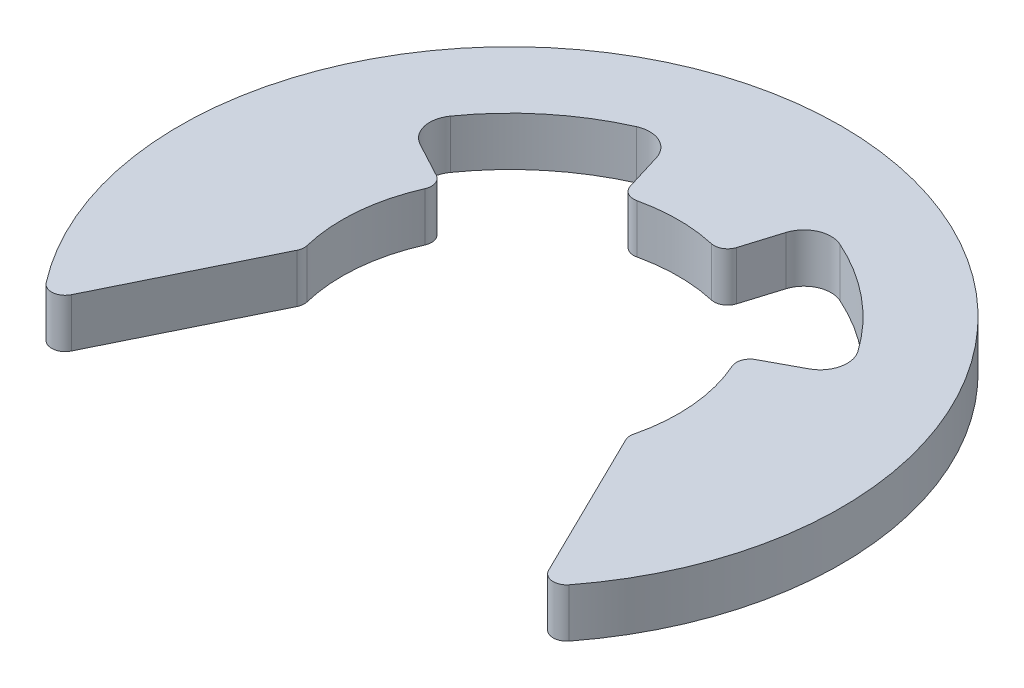
from build123d import *

# Parameters (mm, degrees)
BOSS_EXTRUDE2_DEPTH = 0.9


with BuildPart() as part:
    # Sketch2 → Boss-Extrude2 (new body)
    with BuildSketch(Plane(origin=(0, 0, 0), x_dir=(1, 0, 0), z_dir=(0, 1, 0))):
        with BuildLine():
            Line((-0.980410681, 3.193555213), (-1.194279845, 3.890205091))
            ThreePointArc((-1.194279845, 3.890205091), (-1.465461571, 4.198694788), (-1.876197196, 4.1999862))
            ThreePointArc((-1.876197196, 4.1999862), (-2.921430522, 3.553201895), (-3.758071134, 2.652715844))
            ThreePointArc((-3.758071134, 2.652715844), (-3.836204314, 2.249478162), (-3.585956323, 1.92377682))
            Line((-3.585956323, 1.92377682), (-2.943790684, 1.579270847))
            ThreePointArc((-2.943790684, 1.579270847), (-2.825493737, 1.440063272), (-2.833470582, 1.257554952))
            ThreePointArc((-2.833470582, 1.257554952), (-3.087628894, 0.276672749), (-3.011906881, -0.733768997))
            ThreePointArc((-3.011906881, -0.733768997), (-3.006278091, -0.820065307), (-3.030387689, -0.903116277))
            Line((-3.030387689, -0.903116277), (-4.400044699, -3.693030626))
            ThreePointArc((-4.400044699, -3.693030626), (-4.599153629, -3.831574182), (-4.822086086, -3.735971866))
            ThreePointArc((-4.822086086, -3.735971866), (0, 6.1), (4.822086086, -3.735971866))
            ThreePointArc((4.822086086, -3.735971866), (4.599153629, -3.831574182), (4.400044699, -3.693030626))
            Line((4.400044699, -3.693030626), (3.030387689, -0.903116277))
            ThreePointArc((3.030387689, -0.903116277), (3.006278091, -0.820065307), (3.011906881, -0.733768997))
            ThreePointArc((3.011906881, -0.733768997), (3.087628894, 0.276672749), (2.833470582, 1.257554952))
            ThreePointArc((2.833470582, 1.257554952), (2.825493737, 1.440063272), (2.943790684, 1.579270847))
            Line((2.943790684, 1.579270847), (3.585956323, 1.92377682))
            ThreePointArc((3.585956323, 1.92377682), (3.836204314, 2.249478162), (3.758071134, 2.652715844))
            ThreePointArc((3.758071134, 2.652715844), (2.921430522, 3.553201895), (1.876197196, 4.1999862))
            ThreePointArc((1.876197196, 4.1999862), (1.465461571, 4.198694788), (1.194279845, 3.890205091))
            Line((1.194279845, 3.890205091), (0.980410681, 3.193555213))
            ThreePointArc((0.980410681, 3.193555213), (0.866697189, 3.050579136), (0.68608945, 3.023124421))
            ThreePointArc((0.68608945, 3.023124421), (0, 3.1), (-0.68608945, 3.023124421))
            ThreePointArc((-0.68608945, 3.023124421), (-0.866697189, 3.050579136), (-0.980410681, 3.193555213))
        make_face()
    extrude(amount=BOSS_EXTRUDE2_DEPTH)


solid = part.part
